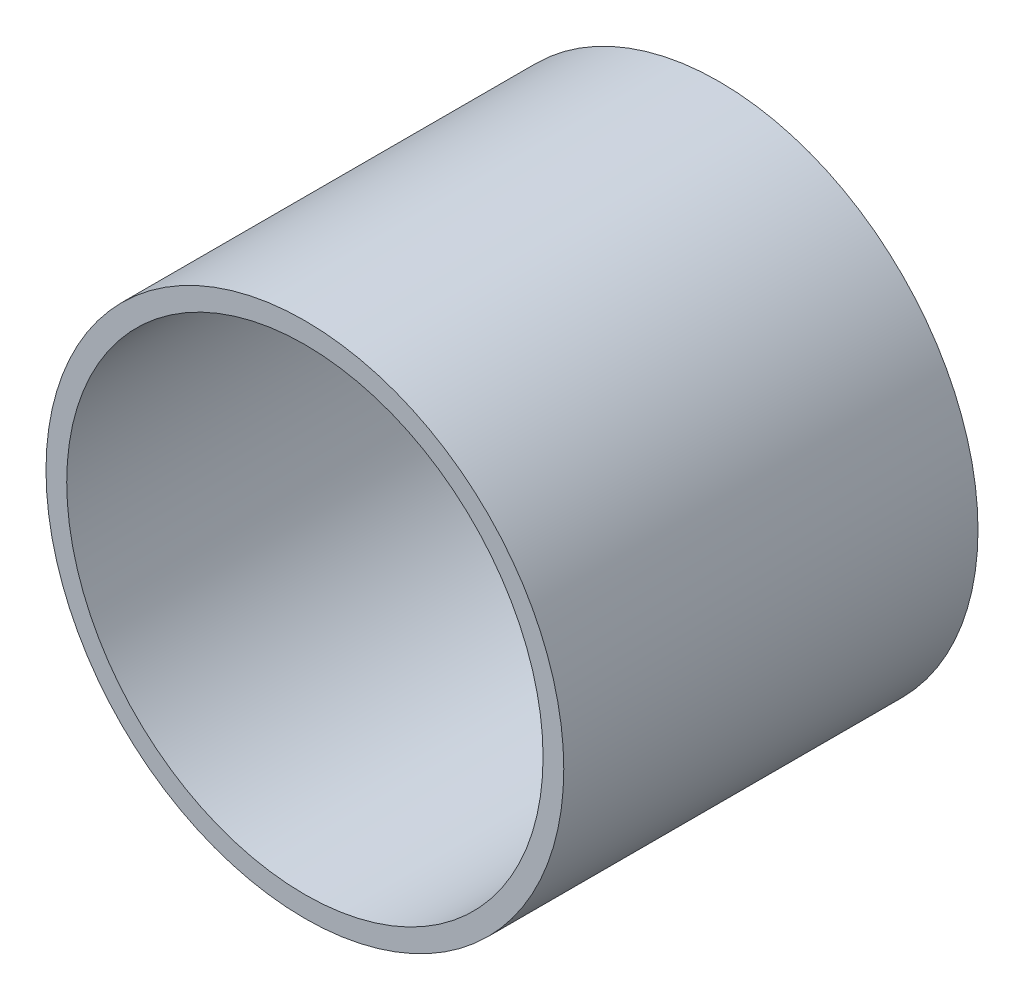
from build123d import *

# Parameters (mm, degrees)
SKETCH1_R           = 79.375
SKETCH1_R_2         = 73.025
BOSS_EXTRUDE1_DEPTH = 127


with BuildPart() as part:
    # Sketch1 → Boss-Extrude1 (new body)
    with BuildSketch(Plane.XY):
        Circle(SKETCH1_R)
        Circle(SKETCH1_R_2, mode=Mode.SUBTRACT)
    extrude(amount=BOSS_EXTRUDE1_DEPTH)


solid = part.part
